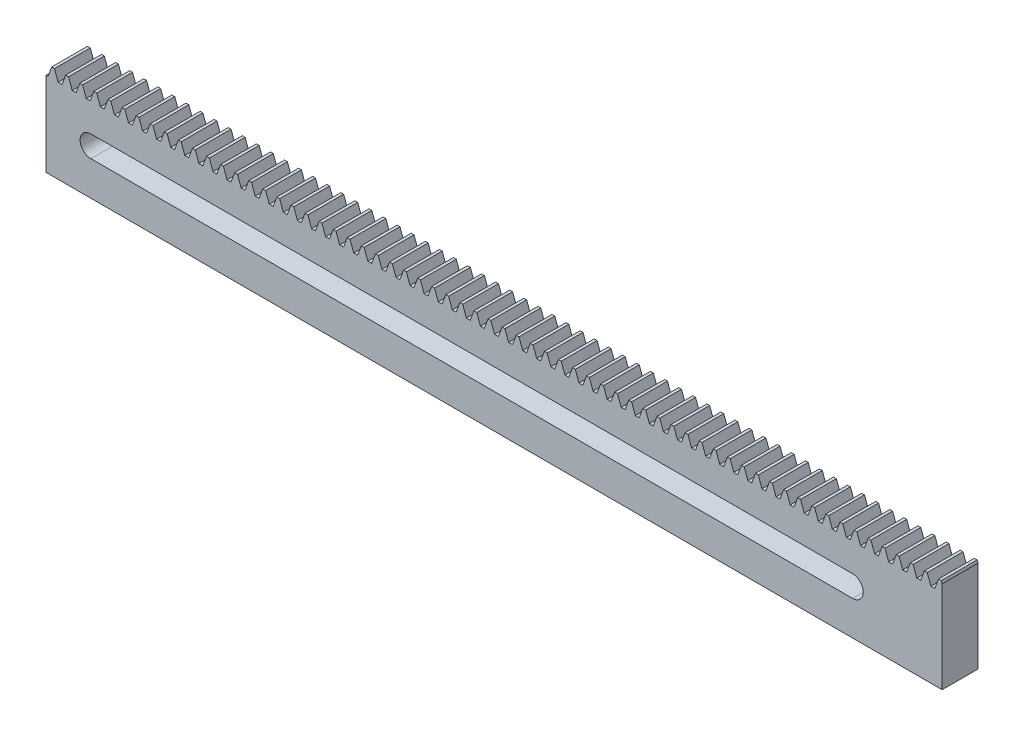
from build123d import *

# Parameters (mm, degrees)
BLANKSKE_W         = 300
BLANKSKE_H         = 31.5
BLANK_DEPTH        = 12
TOOTHCUTSIM_DEPTH  = 302.887810287
TEETHCUTS_COUNT    = 65
TEETHCUTS_PITCH    = 4.712388975
CUT_EXTRUDE2_DEPTH = 302.887810287


with BuildPart() as part:
    # BlankSke → Blank (new body)
    with BuildSketch(Plane.XY):
        with Locations((150, 15.75)):
            Rectangle(BLANKSKE_W, BLANKSKE_H)
    extrude(amount=-BLANK_DEPTH)

    # TooCutSkeSim → ToothCutSim (cut, through all)
    with BuildSketch(Plane.XY):
        Polygon((0.654653055, 28.125), (-0.654653055, 28.125), (-1.892297439, 31.5254), (1.892297439, 31.5254), align=None)
    toothcutsim = extrude(amount=-TOOTHCUTSIM_DEPTH, mode=Mode.SUBTRACT)

    # TeethCuts: ToothCutSim ×65
    with Locations(*[(i * TEETHCUTS_PITCH, 0, 0) for i in range(1, TEETHCUTS_COUNT)]):
        add(toothcutsim, mode=Mode.SUBTRACT)

    # Sketch1 → Cut-Extrude2 (cut, through all)
    with BuildSketch(Plane.XY):
        with BuildLine():
            Line((15, 18.660532337), (270, 18.660532337))
            ThreePointArc((270, 18.660532337), (273.587304659, 15.073227677), (270, 11.485923018))
            Line((270, 11.485923018), (15, 11.485923018))
            ThreePointArc((15, 11.485923018), (11.412695341, 15.073227677), (15, 18.660532337))
        make_face()
    extrude(amount=-CUT_EXTRUDE2_DEPTH, mode=Mode.SUBTRACT)


solid = part.part
